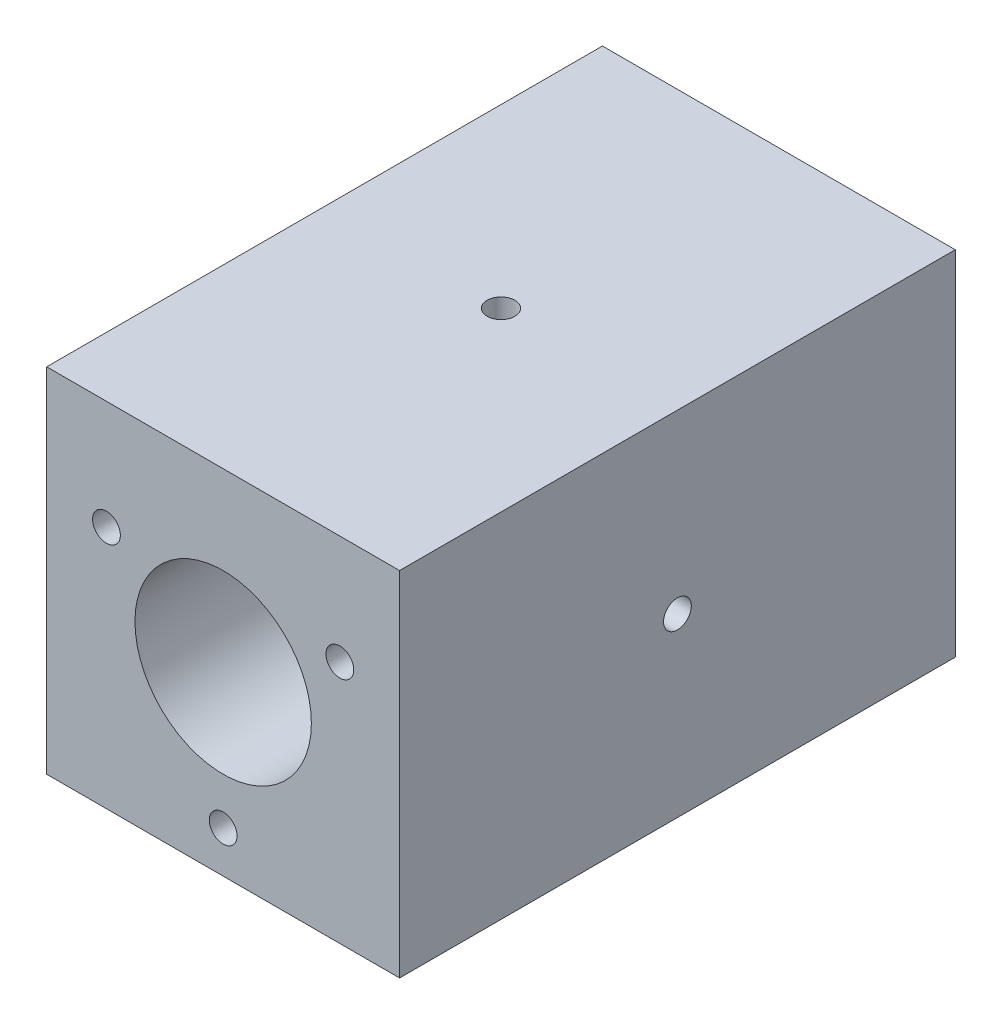
from build123d import *

# Parameters (mm, degrees)
SKETCH1_W                  = 31.75
SKETCH1_H                  = 31.75
SKETCH1_R                  = 7.9375
SKETCH1_R_2                = 1.25
BOSS_EXTRUDE1_DEPTH        = 25
M3X0_5_TAPPED_HOLE1_REACH  = 45.417
M3X0_5_TAPPED_HOLE1_BORE_R = 1.25
M3X0_5_TAPPED_HOLE2_REACH  = 45.417
M3X0_5_TAPPED_HOLE2_BORE_R = 1.25


with BuildPart() as part:
    # Sketch1 → Boss-Extrude1 (new, symmetric)
    with BuildSketch(Plane.XY):
        Rectangle(SKETCH1_W, SKETCH1_H)
        Circle(SKETCH1_R, mode=Mode.SUBTRACT)
        with Locations((-10.5, 6.062177826)):
            Circle(SKETCH1_R_2, mode=Mode.SUBTRACT)
        with Locations((10.5, 6.062177826)):
            Circle(SKETCH1_R_2, mode=Mode.SUBTRACT)
        with Locations((0, -12.124355653)):
            Circle(SKETCH1_R_2, mode=Mode.SUBTRACT)
    extrude(amount=BOSS_EXTRUDE1_DEPTH, both=True)

    # M3x0.5 Tapped Hole1 bore → M3x0.5 Tapped Hole1 (cut, up to next)
    with BuildSketch(Plane(origin=(0, 15.875, 0), x_dir=(1, 0, 0), z_dir=(0, 1, 0)), mode=Mode.PRIVATE) as m3x0_5_tapped_hole1_sk1:
        Circle(M3X0_5_TAPPED_HOLE1_BORE_R)
    m3x0_5_tapped_hole1_tool1 = extrude(m3x0_5_tapped_hole1_sk1.sketch, amount=-M3X0_5_TAPPED_HOLE1_REACH, mode=Mode.PRIVATE) & part.part
    add(m3x0_5_tapped_hole1_tool1.solids().sort_by_distance((0, 15.875, 0))[0], mode=Mode.SUBTRACT)

    # M3x0.5 Tapped Hole2 bore → M3x0.5 Tapped Hole2 (cut, up to next)
    with BuildSketch(Plane(origin=(15.875, 0, 0), x_dir=(0, 0, -1), z_dir=(1, 0, 0)), mode=Mode.PRIVATE) as m3x0_5_tapped_hole2_sk1:
        Circle(M3X0_5_TAPPED_HOLE2_BORE_R)
    m3x0_5_tapped_hole2_tool1 = extrude(m3x0_5_tapped_hole2_sk1.sketch, amount=-M3X0_5_TAPPED_HOLE2_REACH, mode=Mode.PRIVATE) & part.part
    add(m3x0_5_tapped_hole2_tool1.solids().sort_by_distance((15.875, 0, 0))[0], mode=Mode.SUBTRACT)


solid = part.part
